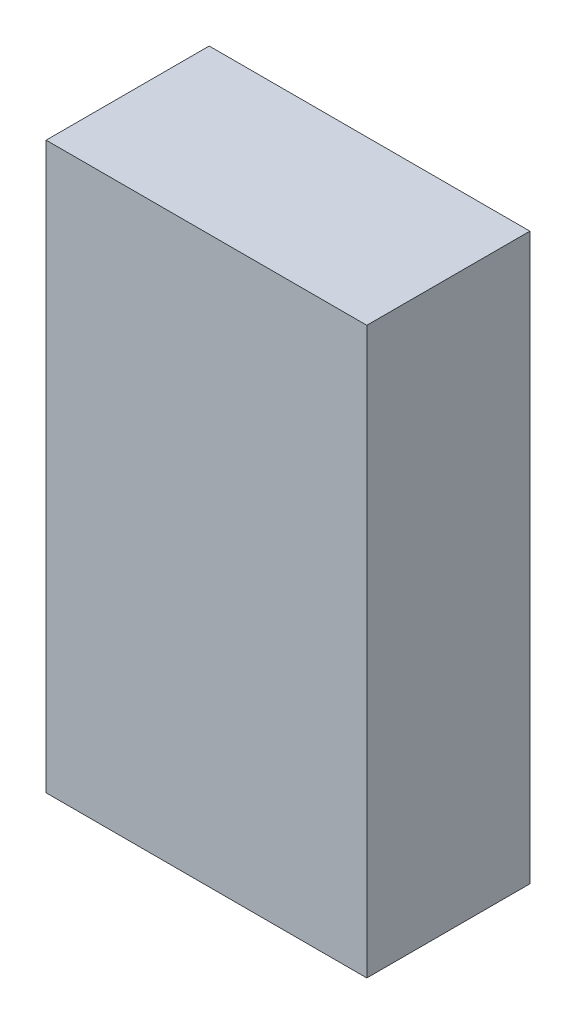
from build123d import *

# Parameters (mm, degrees)
SKETCH1_W           = 749.3
SKETCH1_H           = 381
BOSS_EXTRUDE1_DEPTH = 1320.8


with BuildPart() as part:
    # Sketch1 → Boss-Extrude1 (new body)
    with BuildSketch(Plane(origin=(0, 0, 0), x_dir=(1, 0, 0), z_dir=(0, 1, 0))):
        Rectangle(SKETCH1_W, SKETCH1_H)
    extrude(amount=BOSS_EXTRUDE1_DEPTH)


solid = part.part
